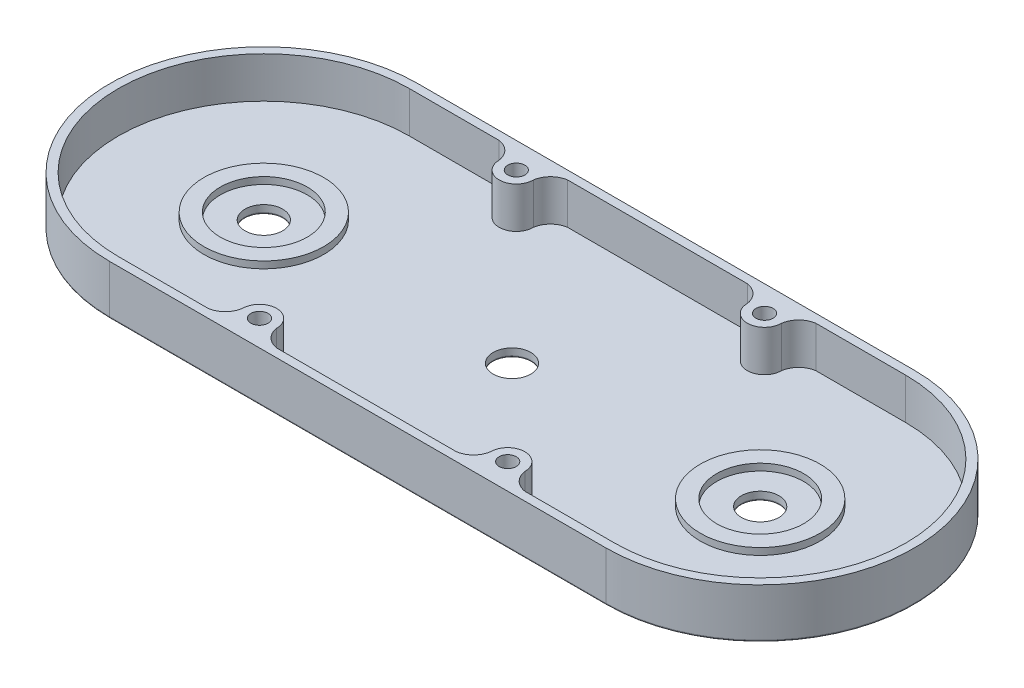
from build123d import *

# Parameters (mm, degrees)
BOSS_EXTRUDE1_DEPTH = 14.5
CUT_EXTRUDE1_DEPTH  = 12
SKETCH3_R           = 17.5
SKETCH3_R_2         = 12.7
BOSS_EXTRUDE2_DEPTH = 2
SKETCH4_R           = 5.5
CUT_EXTRUDE2_DEPTH  = 3.5
BOSS_EXTRUDE4_DEPTH = 12
SKETCH6_R           = 2.5
CUT_EXTRUDE4_DEPTH  = 10
SKETCH7_R           = 5.5
CUT_EXTRUDE5_DEPTH  = 10
FILLET1_R           = 0.5


with BuildPart() as part:
    # Sketch1 → Boss-Extrude1 (new body)
    with BuildSketch(Plane(origin=(0, 0, 0), x_dir=(1, 0, 0), z_dir=(0, 1, 0))):
        with BuildLine():
            Line((0, 45), (145, 45))
            ThreePointArc((145, 45), (190, 0), (145, -45))
            Line((145, -45), (0, -45))
            ThreePointArc((0, -45), (-45, 0), (0, 45))
        make_face()
    extrude(amount=BOSS_EXTRUDE1_DEPTH)

    # Sketch2 → Cut-Extrude1 (cut)
    with BuildSketch(Plane(origin=(0, 14.5, 0), x_dir=(1, 0, 0), z_dir=(0, 1, 0))):
        with BuildLine():
            Line((145, 42.5), (0, 42.5))
            ThreePointArc((0, 42.5), (-42.5, 0), (0, -42.5))
            Line((0, -42.5), (145, -42.5))
            ThreePointArc((145, -42.5), (187.5, 0), (145, 42.5))
        make_face()
    extrude(amount=-CUT_EXTRUDE1_DEPTH, mode=Mode.SUBTRACT)

    # Sketch3 → Boss-Extrude2 (add)
    with BuildSketch(Plane(origin=(0, 2.5, 0), x_dir=(1, 0, 0), z_dir=(0, 1, 0))):
        Circle(SKETCH3_R)
        Circle(SKETCH3_R_2, mode=Mode.SUBTRACT)
        with Locations((145, 0)):
            Circle(SKETCH3_R)
        with Locations((145, 0)):
            Circle(SKETCH3_R_2, mode=Mode.SUBTRACT)
    extrude(amount=BOSS_EXTRUDE2_DEPTH)

    # Sketch4 → Cut-Extrude2 (cut, through all)
    with BuildSketch(Plane(origin=(0, 2.5, 0), x_dir=(1, 0, 0), z_dir=(0, 1, 0))):
        with Locations((72.5, 0)):
            Circle(SKETCH4_R)
    extrude(amount=-CUT_EXTRUDE2_DEPTH, mode=Mode.SUBTRACT)

    # Sketch5 → Boss-Extrude4 (add)
    with BuildSketch(Plane(origin=(0, 2.5, 0), x_dir=(1, 0, 0), z_dir=(0, 1, 0))):
        with BuildLine():
            ThreePointArc((98.75, 42.5), (102.073598273, 40.823598273), (103.75, 37.5))
            ThreePointArc((103.75, 37.5), (108.75, 32.5), (113.75, 37.5))
            ThreePointArc((113.75, 37.5), (115.426401727, 40.823598273), (118.75, 42.5))
            Line((118.75, 42.5), (98.75, 42.5))
        make_face()
        with BuildLine():
            ThreePointArc((41.25, 37.5), (42.926401727, 40.823598273), (46.25, 42.5))
            Line((46.25, 42.5), (26.25, 42.5))
            ThreePointArc((26.25, 42.5), (29.573598273, 40.823598273), (31.25, 37.5))
            ThreePointArc((31.25, 37.5), (36.25, 32.5), (41.25, 37.5))
        make_face()
        with BuildLine():
            Line((98.75, -42.5), (118.75, -42.5))
            ThreePointArc((118.75, -42.5), (115.426401727, -40.823598273), (113.75, -37.5))
            ThreePointArc((113.75, -37.5), (108.75, -32.5), (103.75, -37.5))
            ThreePointArc((103.75, -37.5), (102.073598273, -40.823598273), (98.75, -42.5))
        make_face()
        with BuildLine():
            ThreePointArc((31.25, -37.5), (29.573598273, -40.823598273), (26.25, -42.5))
            Line((26.25, -42.5), (46.25, -42.5))
            ThreePointArc((46.25, -42.5), (42.926401727, -40.823598273), (41.25, -37.5))
            ThreePointArc((41.25, -37.5), (36.25, -32.5), (31.25, -37.5))
        make_face()
    extrude(amount=BOSS_EXTRUDE4_DEPTH)

    # Sketch6 → Cut-Extrude4 (cut)
    with BuildSketch(Plane(origin=(0, 14.5, 0), x_dir=(1, 0, 0), z_dir=(0, 1, 0))):
        with Locations((108.754596876, 37.512242845)):
            Circle(SKETCH6_R)
        with Locations((36.254596876, 37.512242845)):
            Circle(SKETCH6_R)
        with Locations((36.254596876, -37.512242845)):
            Circle(SKETCH6_R)
        with Locations((108.754596876, -37.512242845)):
            Circle(SKETCH6_R)
    extrude(amount=-CUT_EXTRUDE4_DEPTH, mode=Mode.SUBTRACT)

    # Sketch7 → Cut-Extrude5 (cut)
    with BuildSketch(Plane(origin=(0, 2.5, 0), x_dir=(1, 0, 0), z_dir=(0, 1, 0))):
        Circle(SKETCH7_R)
        with Locations((145, 0)):
            Circle(SKETCH7_R)
    extrude(amount=-CUT_EXTRUDE5_DEPTH, mode=Mode.SUBTRACT)

    # Fillet1
    fillet1_edges = [part.edges().sort_by_distance(p)[0] for p in [
        (-5.5, 0, 0),
        (139.5, 0, 0),
        (67, 0, 0),
        (72.5, 0, -45),
        (190, 0, 0),
        (72.5, 0, 45),
        (-45, 0, 0),
    ]]
    fillet(fillet1_edges, radius=FILLET1_R)


solid = part.part
